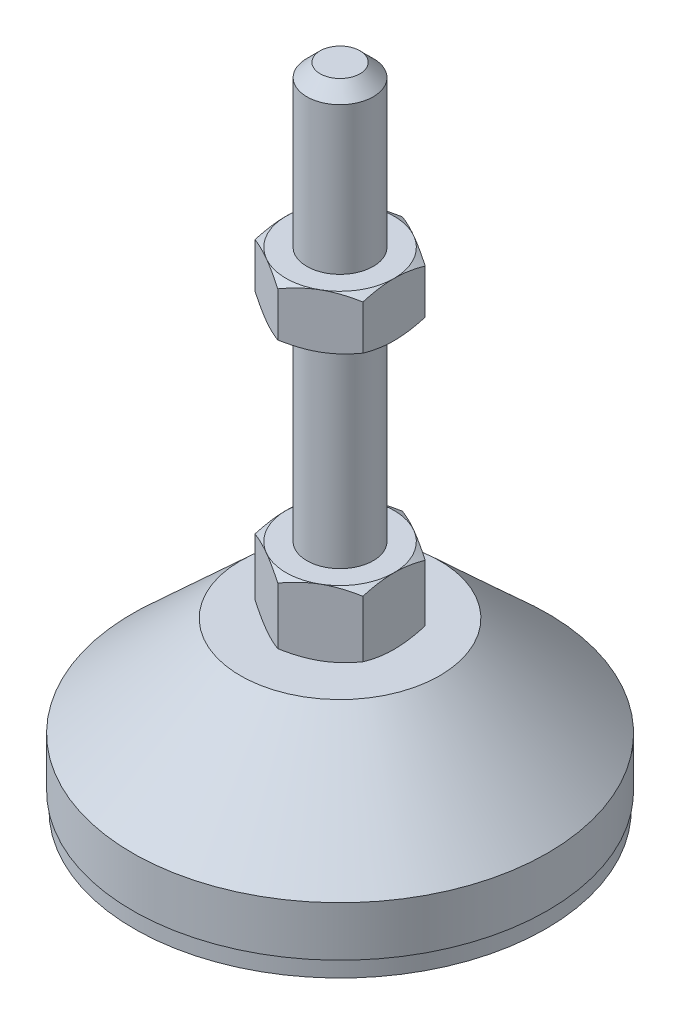
from build123d import *

# Parameters (mm, degrees)
EXTRUDE_1_DEPTH = 8
EXTRUDE_2_DEPTH = 6.5


with BuildPart() as part:
    # Эскиз1 → Повернуть1 (revolve)
    with BuildSketch(Plane.XY, mode=Mode.PRIVATE) as revolve_1_sk:
        Polygon((0, 0), (-24.8, 0), (-24.8, 2), (-25, 2), (-25, 8), (-12, 20), (-4, 20), (-4, 28), (-4, 76.4), (-2.4, 78), (0, 78), align=None)
    revolve(revolve_1_sk.sketch.rotate(Axis((0, 0, 0), (0, 1, 0)), 180), axis=Axis((0, 0, 0), (0, 1, 0)))  # turned: the seam where the file's is

    # Эскиз2 → Бобышка-Вытянуть1 (add)
    with BuildSketch(Plane(origin=(0, 20, 0), x_dir=(1, 0, 0), z_dir=(0, 1, 0))):
        Polygon((0, 7.505553499), (-6.5, 3.75277675), (-6.5, -3.75277675), (0, -7.505553499), (6.5, -3.75277675), (6.5, 3.75277675), align=None)
    extrude(amount=EXTRUDE_1_DEPTH)

    # Эскиз3 → Бобышка-Вытянуть2 (add)
    with BuildSketch(Plane(origin=(0, 52.2, 0), x_dir=(1, 0, 0), z_dir=(0, 1, 0))):
        Polygon((6.5, 3.75277675), (0, 7.505553499), (-6.5, 3.75277675), (-6.5, -3.75277675), (0, -7.505553499), (6.5, -3.75277675), align=None)
    extrude(amount=EXTRUDE_2_DEPTH)

    # Эскиз4 → Вырез-Повернуть2 (revolve, cut)
    with BuildSketch(Plane.XY, mode=Mode.PRIVATE) as cut_revolve_2_sk:
        Polygon((-12.129165125, 58.7), (-6.5, 58.7), (-12.129165125, 55.45), align=None)
        Polygon((-12.129165125, 52.2), (-12.129165125, 55.45), (-6.5, 52.2), align=None)
        Polygon((-13.42820323, 28), (-13.42820323, 24), (-6.5, 28), align=None)
        Polygon((-13.42820323, 24), (-13.42820323, 20), (-6.5, 20), align=None)
    revolve(cut_revolve_2_sk.sketch.rotate(Axis((0, 78, 0), (0, 1, 0)), 180), axis=Axis((0, 78, 0), (0, 1, 0)), mode=Mode.SUBTRACT)  # turned: the seam where the file's is


solid = part.part
